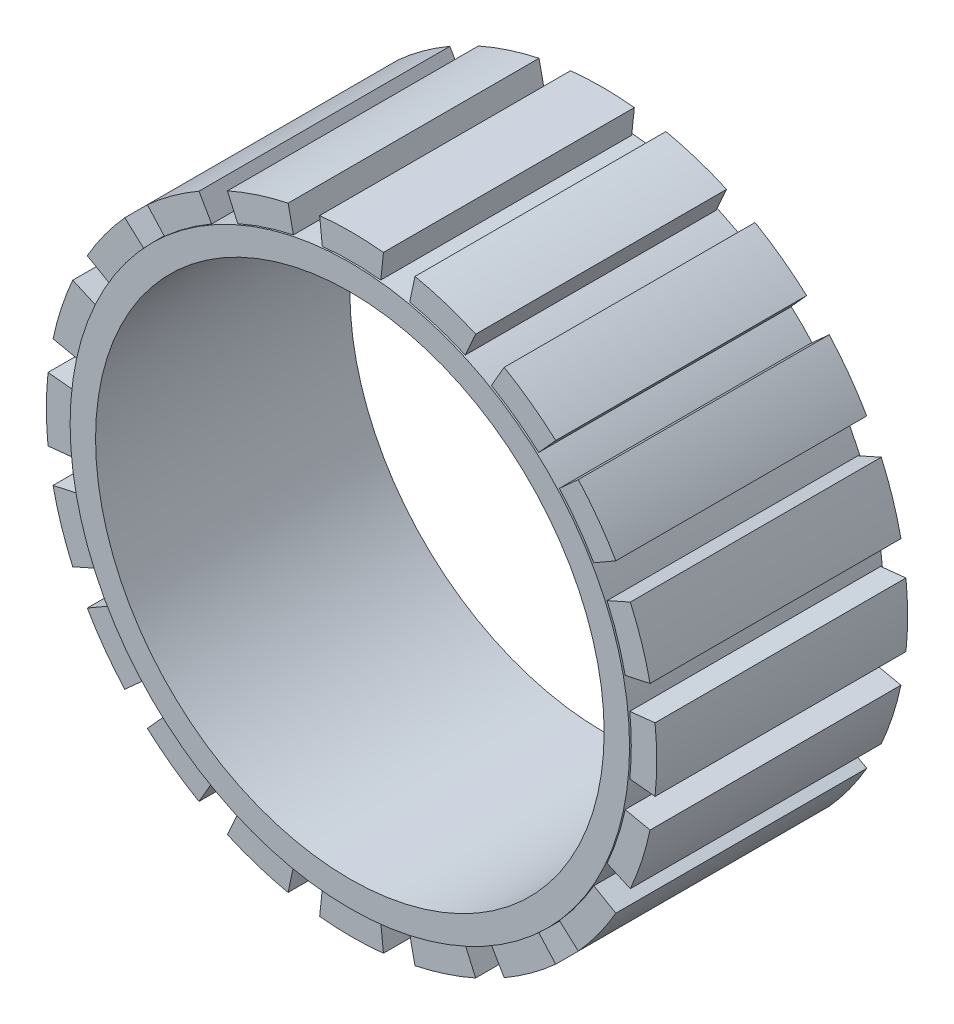
from build123d import *

# Parameters (mm, degrees)
SKETCH1_R           = 16.5
SKETCH1_R_2         = 15
BOSS_EXTRUDE1_DEPTH = 15
BOSS_EXTRUDE3_DEPTH = 14.8
CIRPATTERN1_COUNT   = 20


with BuildPart() as part:
    # Sketch1 → Boss-Extrude1 (new body)
    with BuildSketch(Plane.XY):
        Circle(SKETCH1_R)
        Circle(SKETCH1_R_2, mode=Mode.SUBTRACT)
    extrude(amount=BOSS_EXTRUDE1_DEPTH)

    # Sketch2 → Boss-Extrude3 (add)
    with BuildSketch(Plane(origin=(0, 0, 0.1), x_dir=(-1, 0, 0), z_dir=(0, 0, -1))):
        with BuildLine():
            Line((-1.881512339, 17.901394117), (-1.724719644, 16.409611274))
            ThreePointArc((-1.724719644, 16.409611274), (0, 16.5), (1.724719644, 16.409611274))
            Line((1.724719644, 16.409611274), (1.881512339, 17.901394117))
            ThreePointArc((1.881512339, 17.901394117), (0, 18), (-1.881512339, 17.901394117))
        make_face()
    boss_extrude3 = extrude(amount=-BOSS_EXTRUDE3_DEPTH)

    # CirPattern1: Boss-Extrude3 ×20 about axis
    cirpattern1_axis = Axis((0, 0, 0), (0, 0, 1))
    for i in range(1, CIRPATTERN1_COUNT):
        add(boss_extrude3.rotate(cirpattern1_axis, i * 360 / CIRPATTERN1_COUNT))


solid = part.part
